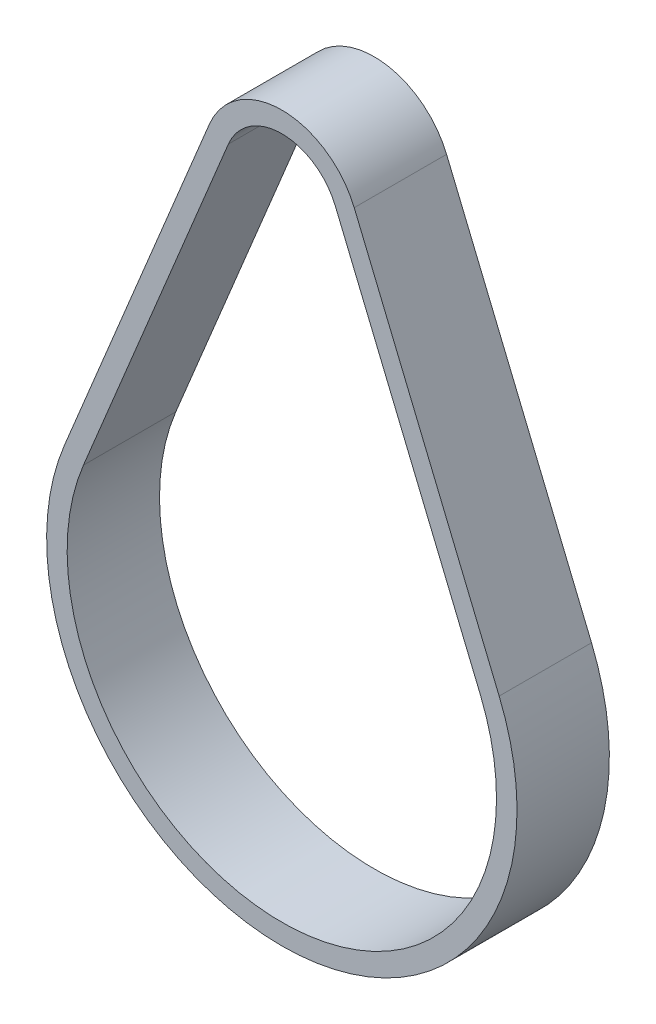
from build123d import *

# Parameters (mm, degrees)
EXTRUDE_THIN1_DEPTH = 4.5


with BuildPart() as part:
    # Sketch1 → Extrude-Thin1 (new body, symmetric)
    with BuildSketch(Plane.XY):
        with BuildLine():
            Line((21.180615986, -31.241695), (7.055584775, 2.917524375))
            ThreePointArc((7.055584775, 2.917524375), (0, 7.635), (-7.055584775, 2.917524375))
            Line((-7.055584775, 2.917524375), (-21.180615986, -31.241695))
            ThreePointArc((-21.180615986, -31.241695), (0, -62.92), (21.180615986, -31.241695))
        make_face()
        with BuildLine():
            Line((19.332394695, -32.005945), (5.207363485, 2.153274375))
            ThreePointArc((5.207363485, 2.153274375), (0, 5.635), (-5.207363485, 2.153274375))
            Line((-5.207363485, 2.153274375), (-19.332394695, -32.005945))
            ThreePointArc((-19.332394695, -32.005945), (0, -60.92), (19.332394695, -32.005945))
        make_face(mode=Mode.SUBTRACT)
    extrude(amount=EXTRUDE_THIN1_DEPTH, both=True)


solid = part.part
